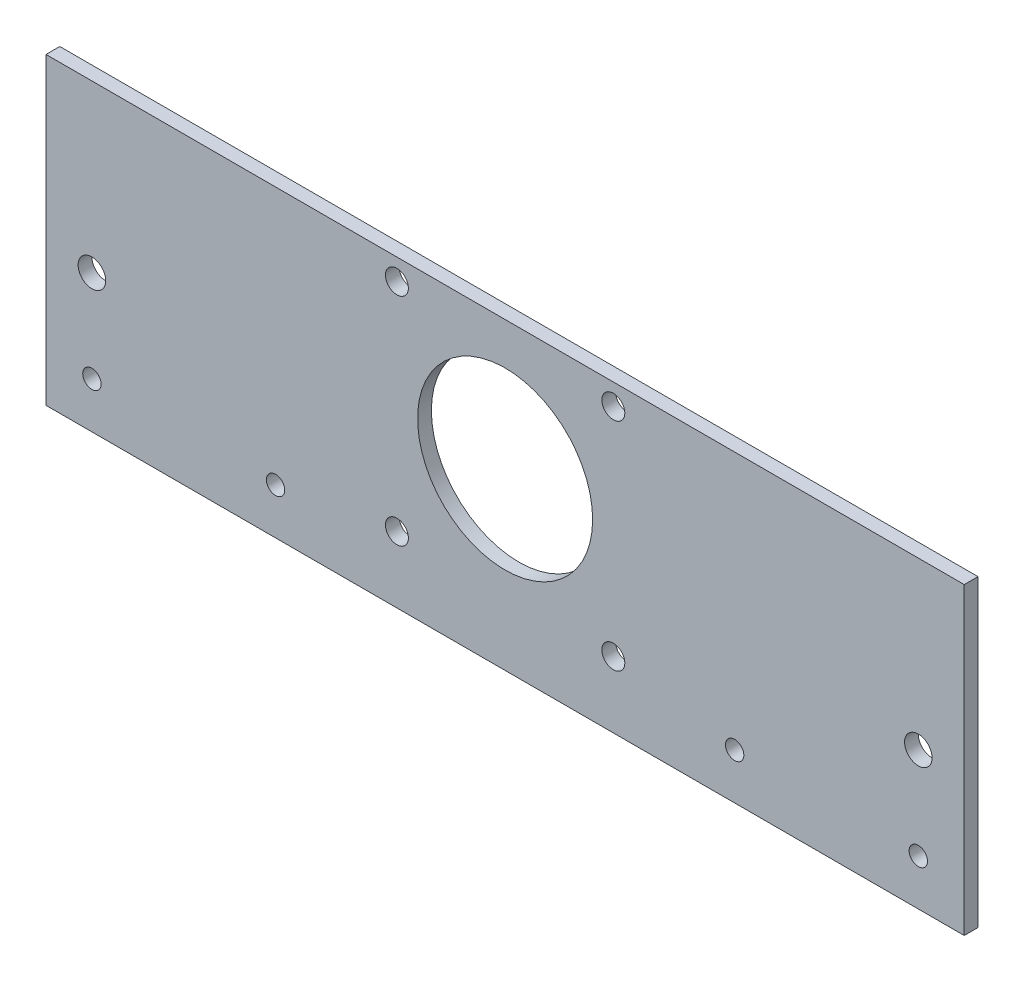
from build123d import *

# Parameters (mm, degrees)
SKIZZE1_W                       = 200
SKIZZE1_H                       = 66.2
AUFSATZ_LINEAR_AUSTRAGEN1_DEPTH = 3
SKIZZE2_R                       = 19.0625
SCHNITT_LINEAR_AUSTRAGEN1_DEPTH = 24
SKIZZE3_R                       = 2
SCHNITT_LINEAR_AUSTRAGEN2_DEPTH = 10
SKIZZE4_R                       = 3
SCHNITT_LINEAR_AUSTRAGEN3_DEPTH = 10
SKIZZE5_R                       = 2.5
SCHNITT_LINEAR_AUSTRAGEN4_DEPTH = 10


with BuildPart() as part:
    # Skizze1 → Aufsatz-Linear austragen1 (new body)
    with BuildSketch(Plane.XY):
        with Locations((100, 33.1)):
            Rectangle(SKIZZE1_W, SKIZZE1_H)
    extrude(amount=AUFSATZ_LINEAR_AUSTRAGEN1_DEPTH)

    # Skizze2 → Schnitt-Linear austragen1 (cut)
    with BuildSketch(Plane.XY.offset(3)):
        with Locations((100, 38)):
            Circle(SKIZZE2_R)
    extrude(amount=-SCHNITT_LINEAR_AUSTRAGEN1_DEPTH, mode=Mode.SUBTRACT)

    # Skizze3 → Schnitt-Linear austragen2 (cut)
    with BuildSketch(Plane(origin=(0, 0, 0), x_dir=(-1, 0, 0), z_dir=(0, 0, -1))):
        with Locations((-190, 10)):
            Circle(SKIZZE3_R)
        with Locations((-150, 10)):
            Circle(SKIZZE3_R)
        with Locations((-50, 10)):
            Circle(SKIZZE3_R)
        with Locations((-10, 10)):
            Circle(SKIZZE3_R)
    extrude(amount=-SCHNITT_LINEAR_AUSTRAGEN2_DEPTH, mode=Mode.SUBTRACT)

    # Skizze4 → Schnitt-Linear austragen3 (cut)
    with BuildSketch(Plane(origin=(0, 0, 0), x_dir=(-1, 0, 0), z_dir=(0, 0, -1))):
        with Locations((-190, 30)):
            Circle(SKIZZE4_R)
        with Locations((-10, 30)):
            Circle(SKIZZE4_R)
    extrude(amount=-SCHNITT_LINEAR_AUSTRAGEN3_DEPTH, mode=Mode.SUBTRACT)

    # Skizze5 → Schnitt-Linear austragen4 (cut)
    with BuildSketch(Plane(origin=(0, 0, 0), x_dir=(-1, 0, 0), z_dir=(0, 0, -1))):
        with Locations((-76.43, 61.57)):
            Circle(SKIZZE5_R)
        with Locations((-123.57, 61.57)):
            Circle(SKIZZE5_R)
        with Locations((-123.57, 14.43)):
            Circle(SKIZZE5_R)
        with Locations((-76.43, 14.43)):
            Circle(SKIZZE5_R)
    extrude(amount=-SCHNITT_LINEAR_AUSTRAGEN4_DEPTH, mode=Mode.SUBTRACT)


solid = part.part
